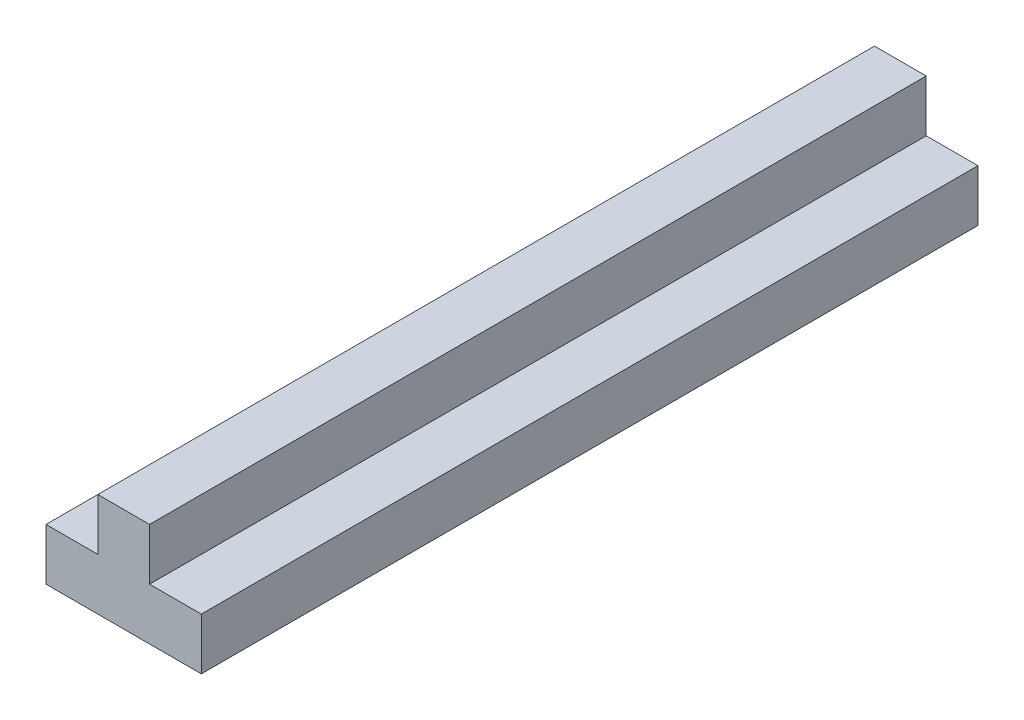
from build123d import *

# Parameters (mm, degrees)
SKETCH1_W           = 12.7
SKETCH1_H           = 2.54
BOSS_EXTRUDE1_DEPTH = 38.1
SKETCH3_W           = 38.1
SKETCH3_H           = 2.54
CUT_EXTRUDE1_DEPTH  = 2.54
SKETCH4_W           = 38.1
SKETCH4_H           = 2.54
CUT_EXTRUDE2_DEPTH  = 2.54
SKETCH5_W           = 2.54
SKETCH5_H           = 38.1
BOSS_EXTRUDE3_DEPTH = 2.54


with BuildPart() as part:
    # Sketch1 → Boss-Extrude1 (new body)
    with BuildSketch(Plane.XY):
        Rectangle(SKETCH1_W, SKETCH1_H)
    extrude(amount=BOSS_EXTRUDE1_DEPTH)

    # Sketch3 → Cut-Extrude1 (cut)
    with BuildSketch(Plane(origin=(6.35, 0, 0), x_dir=(0, 0, -1), z_dir=(1, 0, 0))):
        with Locations((-19.05, 0)):
            Rectangle(SKETCH3_W, SKETCH3_H)
    extrude(amount=-CUT_EXTRUDE1_DEPTH, mode=Mode.SUBTRACT)

    # Sketch4 → Cut-Extrude2 (cut)
    with BuildSketch(Plane.ZY.offset(6.35)):
        with Locations((19.05, 0)):
            Rectangle(SKETCH4_W, SKETCH4_H)
    extrude(amount=-CUT_EXTRUDE2_DEPTH, mode=Mode.SUBTRACT)

    # Sketch5 → Boss-Extrude3 (add)
    with BuildSketch(Plane(origin=(0, 1.27, 0), x_dir=(1, 0, 0), z_dir=(0, 1, 0))):
        with Locations((0, -19.05)):
            Rectangle(SKETCH5_W, SKETCH5_H)
    extrude(amount=BOSS_EXTRUDE3_DEPTH)


solid = part.part
